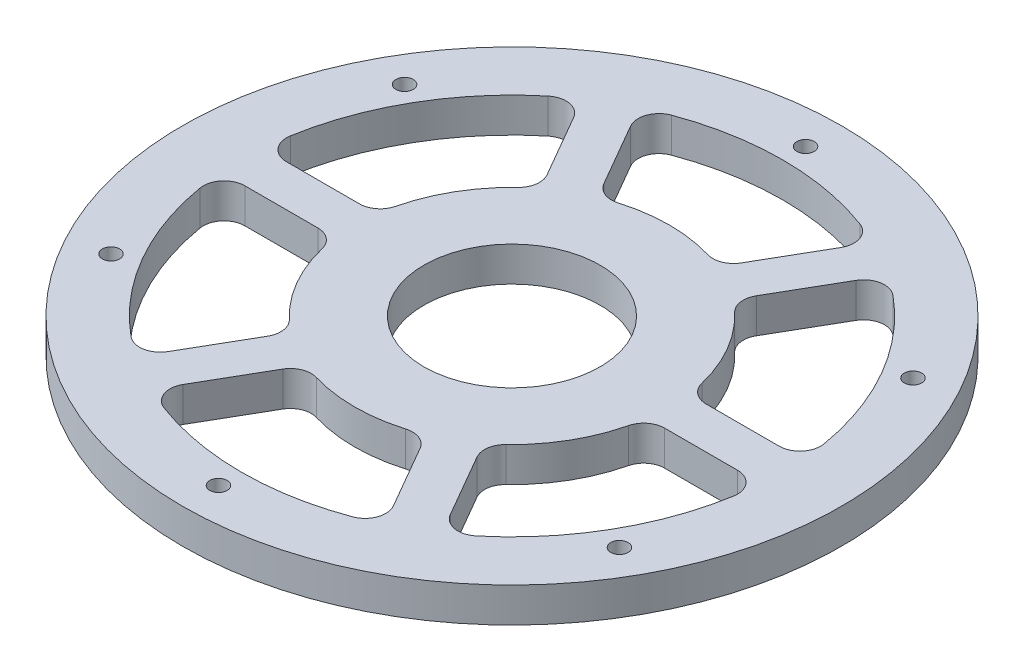
from build123d import *

# Parameters (mm, degrees)
SKETCH1_R           = 47.5
BOSS_EXTRUDE1_DEPTH = 5
SKETCH2_R           = 12.7
CUT_EXTRUDE1_DEPTH  = 6
SKETCH3_R           = 1.25
CUT_EXTRUDE2_DEPTH  = 2.5
CUT_EXTRUDE3_DEPTH  = 6
FILLET1_R           = 3


with BuildPart() as part:
    # Sketch1 → Boss-Extrude1 (new body)
    with BuildSketch(Plane(origin=(0, 0, 0), x_dir=(1, 0, 0), z_dir=(0, 1, 0))):
        Circle(SKETCH1_R)
    extrude(amount=BOSS_EXTRUDE1_DEPTH)

    # Sketch2 → Cut-Extrude1 (cut, through all)
    with BuildSketch(Plane(origin=(0, 5, 0), x_dir=(1, 0, 0), z_dir=(0, 1, 0))):
        Circle(SKETCH2_R)
    extrude(amount=-CUT_EXTRUDE1_DEPTH, mode=Mode.SUBTRACT)

    # Sketch3 → Cut-Extrude2 (cut)
    with BuildSketch(Plane(origin=(0, 5, 0), x_dir=(1, 0, 0), z_dir=(0, 1, 0))):
        with Locations((0, 42.31)):
            Circle(SKETCH3_R)
        with Locations((36.641534834, 21.155)):
            Circle(SKETCH3_R)
        with Locations((36.641534834, -21.155)):
            Circle(SKETCH3_R)
        with Locations((0, -42.31)):
            Circle(SKETCH3_R)
        with Locations((-36.641534834, -21.155)):
            Circle(SKETCH3_R)
        with Locations((-36.641534834, 21.155)):
            Circle(SKETCH3_R)
    extrude(amount=-CUT_EXTRUDE2_DEPTH, mode=Mode.SUBTRACT)

    # Sketch4 → Cut-Extrude3 (cut, through all)
    with BuildSketch(Plane(origin=(0, 5, 0), x_dir=(1, 0, 0), z_dir=(0, 1, 0))):
        with BuildLine():
            Line((-13.848520647, 17.98634137), (-22.040298307, 32.174916481))
            ThreePointArc((-22.040298307, 32.174916481), (-33.774990748, 19.5), (-38.88444419, 3))
            Line((-38.88444419, 3), (-22.500888871, 3))
            ThreePointArc((-22.500888871, 3), (-19.658776666, 11.35), (-13.848520647, 17.98634137))
        make_face()
        with BuildLine():
            ThreePointArc((16.844145884, 35.174916481), (0, 39), (-16.844145884, 35.174916481))
            Line((-16.844145884, 35.174916481), (-8.652368224, 20.98634137))
            ThreePointArc((-8.652368224, 20.98634137), (0, 22.7), (8.652368224, 20.98634137))
            Line((8.652368224, 20.98634137), (16.844145884, 35.174916481))
        make_face()
        with BuildLine():
            ThreePointArc((38.88444419, 3), (33.774990748, 19.5), (22.040298307, 32.174916481))
            Line((22.040298307, 32.174916481), (13.848520647, 17.98634137))
            ThreePointArc((13.848520647, 17.98634137), (19.658776666, 11.35), (22.500888871, 3))
            Line((22.500888871, 3), (38.88444419, 3))
        make_face()
        with BuildLine():
            ThreePointArc((22.040298307, -32.174916481), (33.774990748, -19.5), (38.88444419, -3))
            Line((38.88444419, -3), (22.500888871, -3))
            ThreePointArc((22.500888871, -3), (19.658776666, -11.35), (13.848520647, -17.98634137))
            Line((13.848520647, -17.98634137), (22.040298307, -32.174916481))
        make_face()
        with BuildLine():
            Line((-8.652368224, -20.98634137), (-16.844145884, -35.174916481))
            ThreePointArc((-16.844145884, -35.174916481), (0, -39), (16.844145884, -35.174916481))
            Line((16.844145884, -35.174916481), (8.652368224, -20.98634137))
            ThreePointArc((8.652368224, -20.98634137), (0, -22.7), (-8.652368224, -20.98634137))
        make_face()
        with BuildLine():
            Line((-22.500888871, -3), (-38.88444419, -3))
            ThreePointArc((-38.88444419, -3), (-33.774990748, -19.5), (-22.040298307, -32.174916481))
            Line((-22.040298307, -32.174916481), (-13.848520647, -17.98634137))
            ThreePointArc((-13.848520647, -17.98634137), (-19.658776666, -11.35), (-22.500888871, -3))
        make_face()
    extrude(amount=-CUT_EXTRUDE3_DEPTH, mode=Mode.SUBTRACT)

    # Fillet1
    fillet1_edges = [part.edges().sort_by_distance(p)[0] for p in [
        (22.500888871, 2.5, -3),
        (13.848520647, 2.5, -17.98634137),
        (22.040298307, 2.5, -32.174916481),
        (38.88444419, 2.5, -3),
        (8.652368224, 2.5, -20.98634137),
        (-8.652368224, 2.5, -20.98634137),
        (-16.844145884, 2.5, -35.174916481),
        (16.844145884, 2.5, -35.174916481),
        (-8.652368224, 2.5, 20.98634137),
        (8.652368224, 2.5, 20.98634137),
        (16.844145884, 2.5, 35.174916481),
        (-16.844145884, 2.5, 35.174916481),
        (13.848520647, 2.5, 17.98634137),
        (22.500888871, 2.5, 3),
        (38.88444419, 2.5, 3),
        (22.040298307, 2.5, 32.174916481),
        (-22.500888871, 2.5, 3),
        (-13.848520647, 2.5, 17.98634137),
        (-22.040298307, 2.5, 32.174916481),
        (-38.88444419, 2.5, 3),
        (-13.848520647, 2.5, -17.98634137),
        (-22.500888871, 2.5, -3),
        (-38.88444419, 2.5, -3),
        (-22.040298307, 2.5, -32.174916481),
    ]]
    fillet(fillet1_edges, radius=FILLET1_R)


solid = part.part
